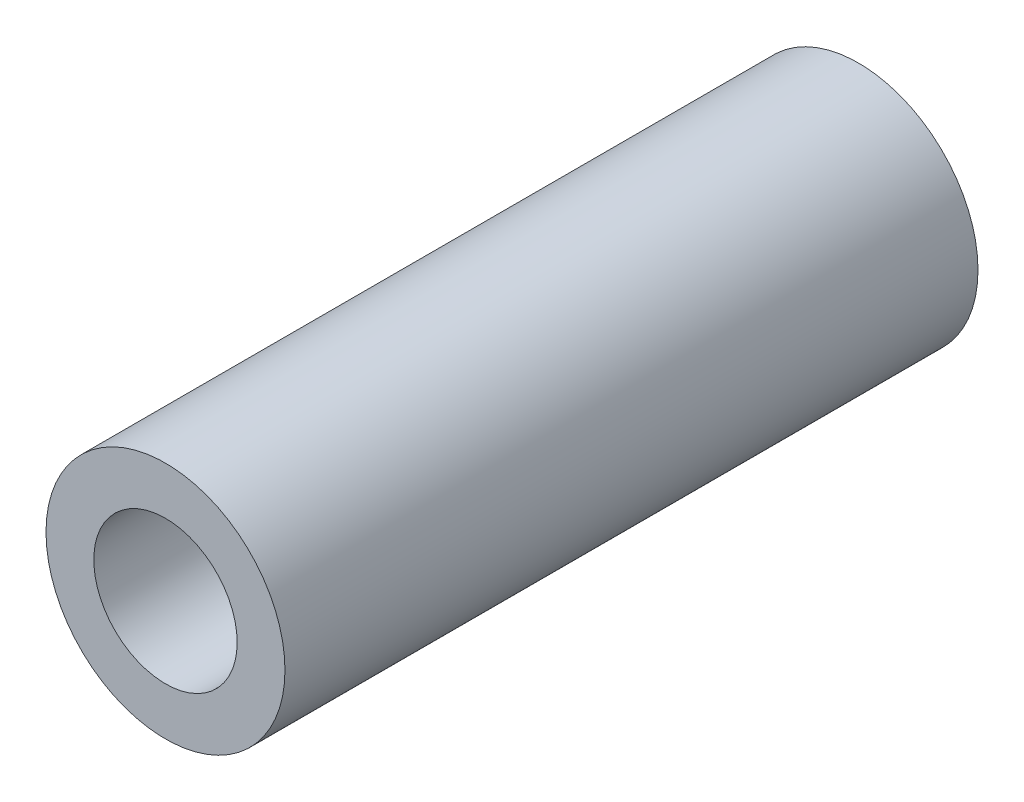
from build123d import *

# Parameters (mm, degrees)
SKETCH2_R           = 2.5
SKETCH2_R_2         = 1.5
BOSS_EXTRUDE1_DEPTH = 14.5


with BuildPart() as part:
    # Sketch2 → Boss-Extrude1 (new body)
    with BuildSketch(Plane.XY):
        Circle(SKETCH2_R)
        Circle(SKETCH2_R_2, mode=Mode.SUBTRACT)
    extrude(amount=BOSS_EXTRUDE1_DEPTH)


solid = part.part
